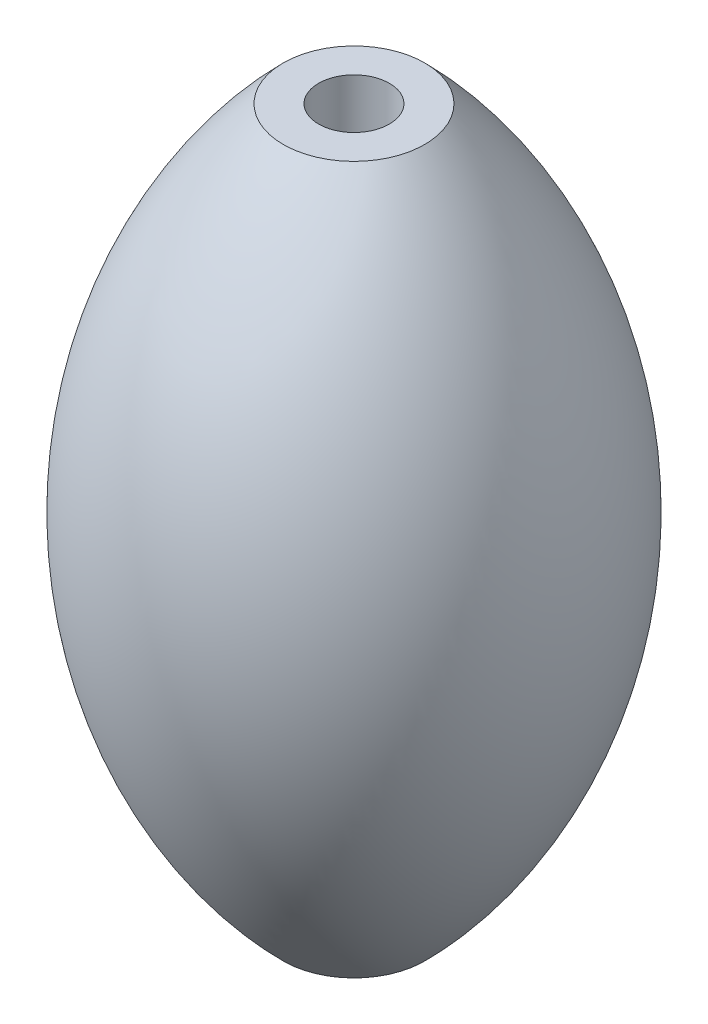
from build123d import *

# Parameters (mm, degrees)
SKETCH2_R          = 0.5
CUT_EXTRUDE1_DEPTH = 11.0000001


with BuildPart() as part:
    # Sketch1 → Revolve1 (revolve)
    with BuildSketch(Plane.XY):
        with BuildLine():
            ThreePointArc((1, 5), (3.071067812, 0), (1, -5))
            Line((1, -5), (0, -5))
            Line((0, -5), (0, 5))
            Line((0, 5), (1, 5))
        make_face()
    revolve(axis=Axis((0, 5, 0), (0, -1, 0)))

    # Sketch2 → Cut-Extrude1 (cut, through all)
    with BuildSketch(Plane(origin=(0, 5, 0), x_dir=(1, 0, 0), z_dir=(0, 1, 0))):
        Circle(SKETCH2_R)
    extrude(amount=-CUT_EXTRUDE1_DEPTH, mode=Mode.SUBTRACT)


solid = part.part
